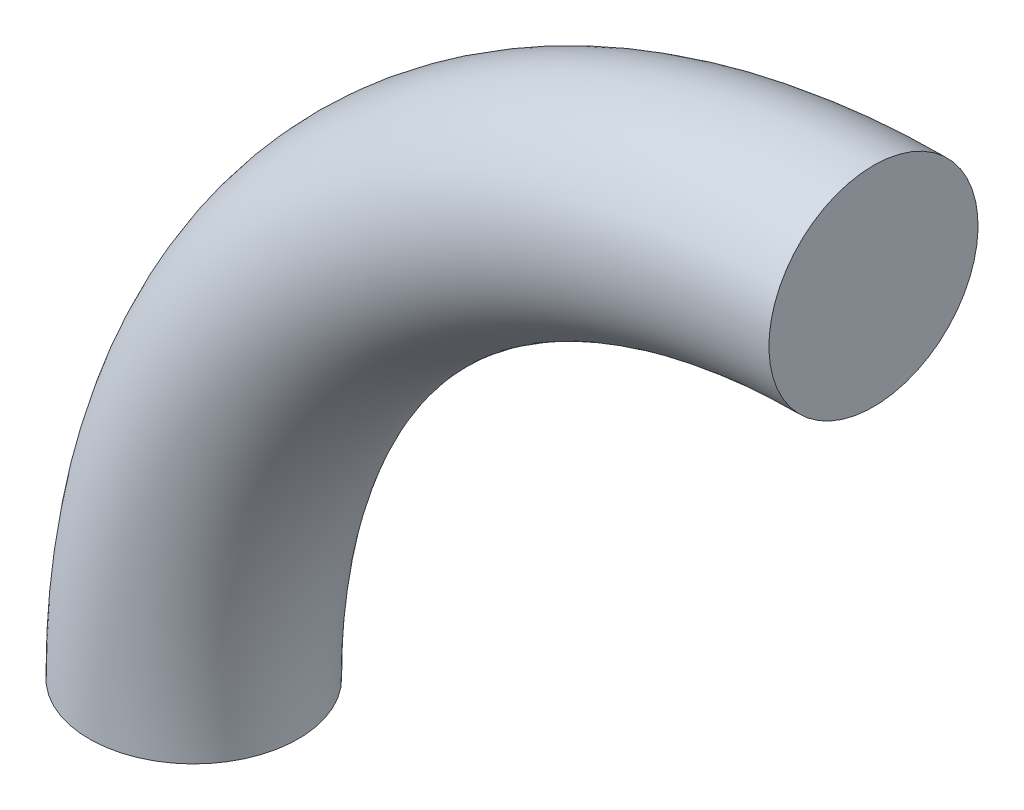
from build123d import *

# Parameters (mm, degrees)
SKETCH2_R = 10


with BuildPart() as part:
    # Sweep1: sweep along a path in Sketch1
    with BuildLine(Plane.XY) as sweep1_path:
        ThreePointArc((0, 0), (19.038059223, 45.961940777), (65, 65))
    # Sketch2 → Sweep1 (sweep)
    with BuildSketch(Plane(origin=(0, 0, 0), x_dir=(1, 0, 0), z_dir=(0, 1, 0))):
        Circle(SKETCH2_R)
    sweep(path=sweep1_path.line)


solid = part.part
